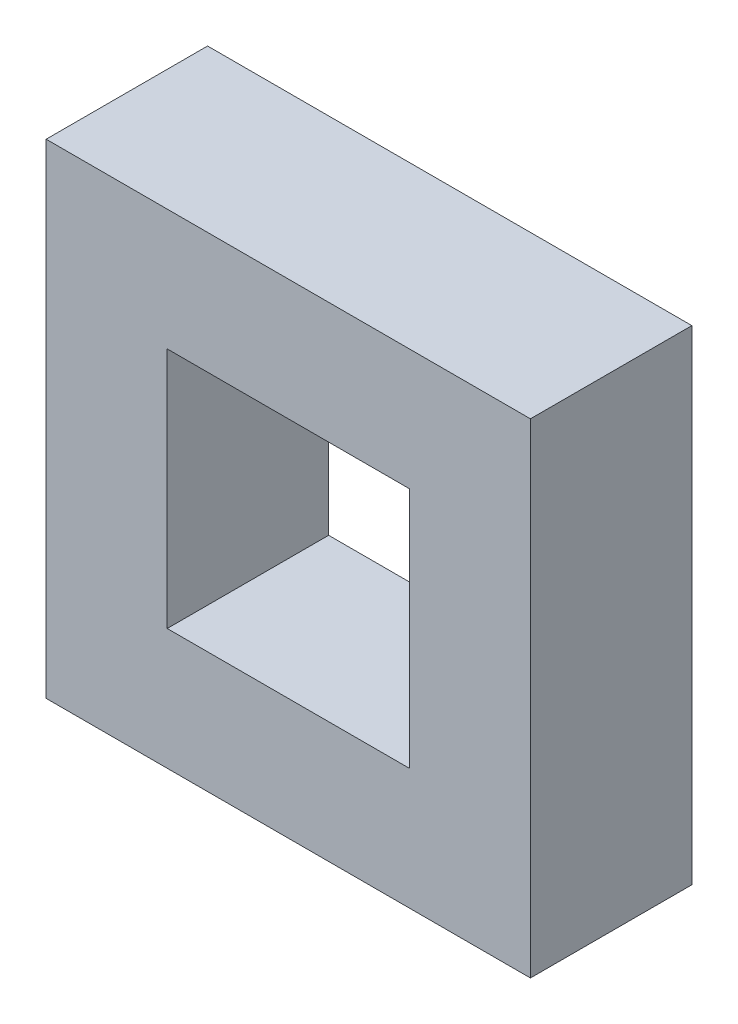
from build123d import *

# Parameters (mm, degrees)
SKETCH1_W           = 76.2
SKETCH1_H           = 76.2
BOSS_EXTRUDE1_DEPTH = 12.7
SKETCH2_W           = 38.1
SKETCH2_H           = 38.1
CUT_EXTRUDE1_DEPTH  = 26.4


with BuildPart() as part:
    # Sketch1 → Boss-Extrude1 (new body, symmetric)
    with BuildSketch(Plane.XY):
        Rectangle(SKETCH1_W, SKETCH1_H)
    extrude(amount=BOSS_EXTRUDE1_DEPTH, both=True)

    # Sketch2 → Cut-Extrude1 (cut, through all)
    with BuildSketch(Plane.XY.offset(12.7)):
        Rectangle(SKETCH2_W, SKETCH2_H)
    extrude(amount=-CUT_EXTRUDE1_DEPTH, mode=Mode.SUBTRACT)


solid = part.part
